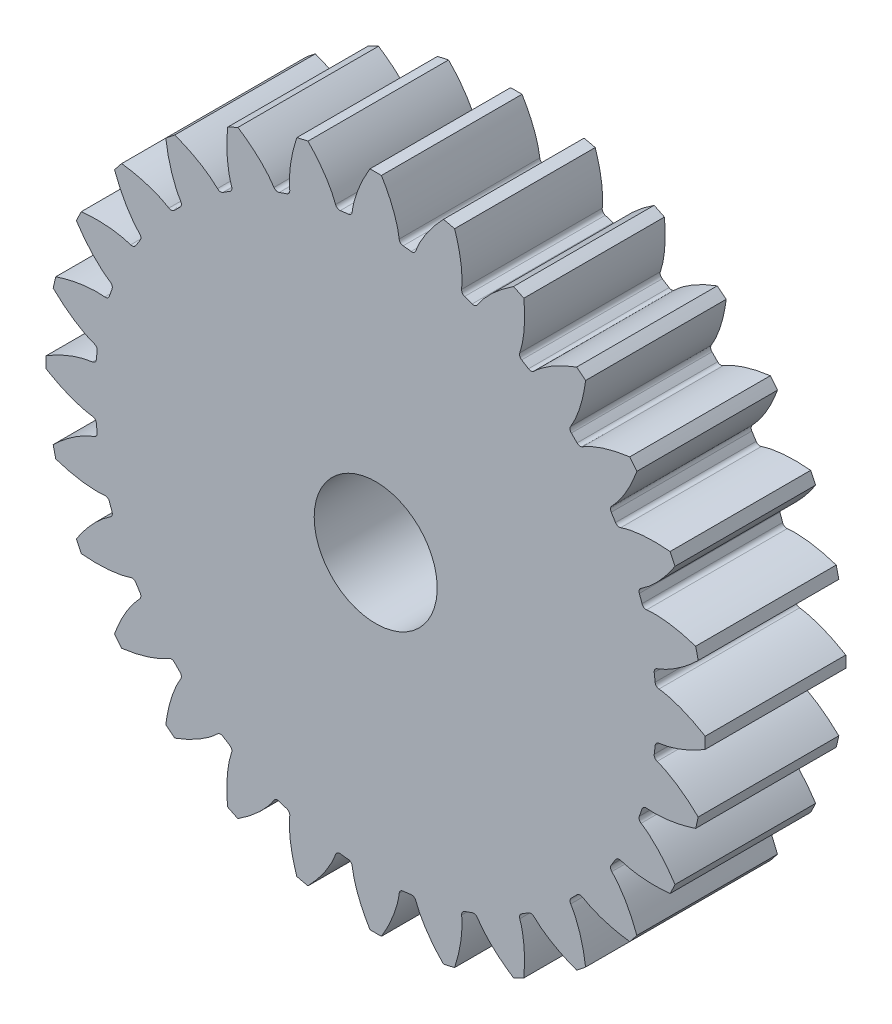
from build123d import *

# Parameters (mm, degrees)
CROQUIS1_R              = 7
SALIENTE_EXTRUIR1_DEPTH = 16


with BuildPart() as part:
    # Croquis1 → Saliente-Extruir1 (new body)
    with BuildSketch(Plane.XY.offset(16)):
        with BuildLine():
            ThreePointArc((26.6938963, -4.031185896), (26.748350108, -3.577124719), (26.796299165, -3.122330636))
            ThreePointArc((26.796299165, -3.122330636), (26.937385185, -2.820846865), (27.236373236, -2.674546235))
            add(Edge.make_bspline(
                [(27.236373236, -2.674546235), (29.642937848, -2.384409161), (32.494335404, -0.652262326)],
                knots=[3.829860465, 3.829860465, 3.829860465, 4.565475677, 4.565475677, 4.565475677], degree=2, weights=[1, 0.933117908, 1]))
            ThreePointArc((32.494335404, -0.652262326), (32.500009079, 5.4516e-05), (32.49433477, 0.652371352))
            add(Edge.make_bspline(
                [(32.49433477, 0.652371352), (29.642538779, 2.385172106), (27.236372217, 2.674655637)],
                knots=[1.705602873, 1.705602873, 1.705602873, 2.450147181, 2.450147181, 2.450147181], degree=2, weights=[1, 0.931503294, 1]))
            ThreePointArc((27.236372217, 2.674655637), (26.937384176, 2.820956256), (26.796298149, 3.122440008))
            ThreePointArc((26.796298149, 3.122440008), (26.748350621, 3.577215817), (26.693898866, 4.031258776))
            ThreePointArc((26.693898866, 4.031258776), (26.764362513, 4.356577558), (27.023298054, 4.565742136))
            add(Edge.make_bspline(
                [(27.023298054, 4.565742136), (29.304963609, 5.384115916), (31.699431838, 7.707330023)],
                knots=[0.688267811, 0.688267811, 0.688267811, 1.423883058, 1.423883058, 1.423883058], degree=2, weights=[1, 0.933117902, 1]))
            ThreePointArc((31.699431838, 7.707330023), (31.559805686, 8.344572282), (31.409115452, 8.979289236))
            add(Edge.make_bspline(
                [(31.409115452, 8.979289236), (28.243235754, 10.034060578), (25.832980864, 9.780863743)],
                knots=[1.705602929, 1.705602929, 1.705602929, 2.450147181, 2.450147181, 2.450147181], degree=2, weights=[1, 0.931503304, 1]))
            ThreePointArc((25.832980864, 9.780863743), (25.508936625, 9.856969646), (25.304298481, 10.119495849))
            ThreePointArc((25.304298481, 10.119495849), (25.15635596, 10.55220015), (25.002235361, 10.982742648))
            ThreePointArc((25.002235361, 10.982742648), (24.998546388, 11.315583457), (25.204442252, 11.577124095))
            add(Edge.make_bspline(
                [(25.204442252, 11.577124095), (27.246796244, 12.882697794), (29.0642663, 15.680483123)],
                knots=[0.688267812, 0.688267812, 0.688267812, 1.42388301, 1.42388301, 1.42388301], degree=2, weights=[1, 0.93311791, 1]))
            ThreePointArc((29.0642663, 15.680483123), (28.786341176, 16.270678535), (28.498191306, 16.855949968))
            add(Edge.make_bspline(
                [(28.498191306, 16.855949968), (25.176978278, 17.179801421), (22.883495213, 16.396620625)],
                knots=[1.70560296, 1.70560296, 1.70560296, 2.450147181, 2.450147181, 2.450147181], degree=2, weights=[1, 0.93150331, 1]))
            ThreePointArc((22.883495213, 16.396620625), (22.550641093, 16.398714506), (22.292714958, 16.609119731))
            ThreePointArc((22.292714958, 16.609119731), (22.052195901, 16.998054924), (21.806134708, 17.383507762))
            ThreePointArc((21.806134708, 17.383507762), (21.728476527, 17.707182576), (21.871009564, 18.007982362))
            add(Edge.make_bspline(
                [(21.871009564, 18.007982362), (23.571639933, 19.735289056), (24.720976404, 22.867353058)],
                knots=[3.829860466, 3.829860466, 3.829860466, 4.565475639, 4.565475639, 4.565475639], degree=2, weights=[1, 0.933117915, 1]))
            ThreePointArc((24.720976404, 22.867353058), (24.318688643, 23.380906834), (23.907528182, 23.887384868))
            add(Edge.make_bspline(
                [(23.907528182, 23.887384868), (20.597521234, 23.464077255), (18.535814735, 22.190184465)],
                knots=[4.847195625, 4.847195625, 4.847195625, 5.591739835, 5.591739835, 5.591739835], degree=2, weights=[1, 0.931503312, 1]))
            ThreePointArc((18.535814735, 22.190184465), (18.210840096, 22.118159884), (17.912560955, 22.265894815))
            ThreePointArc((17.912560955, 22.265894815), (17.59152599, 22.591558065), (17.26586274, 22.91259303))
            ThreePointArc((17.26586274, 22.91259303), (17.118127789, 23.210872177), (17.190152368, 23.535846831))
            add(Edge.make_bspline(
                [(17.190152368, 23.535846831), (18.463782472, 25.598272177), (18.887352876, 28.907560184)],
                knots=[0.688267813, 0.688267813, 0.688267813, 1.423882978, 1.423882978, 1.423882978], degree=2, weights=[1, 0.933117916, 1]))
            ThreePointArc((18.887352876, 28.907560184), (18.380874844, 29.318720646), (17.867321069, 29.721008408))
            add(Edge.make_bspline(
                [(17.867321069, 29.721008408), (14.734497675, 28.57176816), (13.007950258, 26.87104165)],
                knots=[1.705602965, 1.705602965, 1.705602965, 2.450147181, 2.450147181, 2.450147181], degree=2, weights=[1, 0.93150331, 1]))
            ThreePointArc((13.007950258, 26.87104165), (12.707150487, 26.728508615), (12.383475684, 26.806166778))
            ThreePointArc((12.383475684, 26.806166778), (11.998022845, 27.05222797), (11.609087652, 27.292747027))
            ThreePointArc((11.609087652, 27.292747027), (11.398682406, 27.550673163), (11.39658852, 27.883527298))
            add(Edge.make_bspline(
                [(11.39658852, 27.883527298), (12.179353257, 30.177652733), (11.855917987, 33.498223322)],
                knots=[0.688267812, 0.688267812, 0.688267812, 1.42388299, 1.42388299, 1.42388299], degree=2, weights=[1, 0.933117914, 1]))
            ThreePointArc((11.855917987, 33.498223322), (11.270646555, 33.786373193), (10.680451145, 34.064298319))
            add(Edge.make_bspline(
                [(10.680451145, 34.064298319), (7.881904052, 32.246753093), (6.577091985, 30.204474326)],
                knots=[4.847195593, 4.847195593, 4.847195593, 5.591739835, 5.591739835, 5.591739835], degree=2, weights=[1, 0.931503306, 1]))
            ThreePointArc((6.577091985, 30.204474326), (6.315551361, 29.998578466), (5.982710566, 30.002267424))
            ThreePointArc((5.982710566, 30.002267424), (5.552168068, 30.156388023), (5.119463767, 30.304330543))
            ThreePointArc((5.119463767, 30.304330543), (4.856937544, 30.508968685), (4.780831632, 30.833012936))
            add(Edge.make_bspline(
                [(4.780831632, 30.833012936), (5.033479902, 33.243801508), (3.979257264, 36.409147485)],
                knots=[0.688267812, 0.688267812, 0.688267812, 1.42388302, 1.42388302, 1.42388302], degree=2, weights=[1, 0.933117908, 1]))
            ThreePointArc((3.979257264, 36.409147485), (3.344540327, 36.559837717), (2.707298086, 36.699463867))
            add(Edge.make_bspline(
                [(2.707298086, 36.699463867), (0.383358091, 34.304752876), (-0.43428988, 32.023330174)],
                knots=[1.705602901, 1.705602901, 1.705602901, 2.450147181, 2.450147181, 2.450147181], degree=2, weights=[1, 0.931503299, 1]))
            ThreePointArc((-0.43428988, 32.023330174), (-0.643455006, 31.764395442), (-0.968773306, 31.693930923))
            ThreePointArc((-0.968773306, 31.693930923), (-1.422816265, 31.748382677), (-1.877592074, 31.796330205))
            ThreePointArc((-1.877592074, 31.796330205), (-2.179073064, 31.937419401), (-2.325376822, 32.236404617))
            add(Edge.make_bspline(
                [(-2.325376822, 32.236404617), (-2.615513901, 34.642969248), (-4.347660757, 37.494366823)],
                knots=[3.829860465, 3.829860465, 3.829860465, 4.565475683, 4.565475683, 4.565475683], degree=2, weights=[1, 0.933117907, 1]))
            ThreePointArc((-4.347660757, 37.494366823), (-4.999995664, 37.500041132), (-5.652330571, 37.494366827))
            add(Edge.make_bspline(
                [(-5.652330571, 37.494366827), (-7.385130954, 34.642571184), (-7.674614446, 32.23640495)],
                knots=[4.847195619, 4.847195619, 4.847195619, 5.591739835, 5.591739835, 5.591739835], degree=2, weights=[1, 0.93150331, 1]))
            ThreePointArc((-7.674614446, 32.23640495), (-7.820921304, 31.937422565), (-8.122399509, 31.796330202))
            ThreePointArc((-8.122399509, 31.796330202), (-8.577175317, 31.748382674), (-9.031218274, 31.693930919))
            ThreePointArc((-9.031218274, 31.693930919), (-9.35653325, 31.764401622), (-9.565702422, 32.023330592))
            add(Edge.make_bspline(
                [(-9.565702422, 32.023330592), (-10.384076099, 34.304995852), (-12.707289789, 36.699463835)],
                knots=[0.688267813, 0.688267813, 0.688267813, 1.423882972, 1.423882972, 1.423882972], degree=2, weights=[1, 0.933117917, 1]))
            ThreePointArc((-12.707289789, 36.699463835), (-13.344531798, 36.559837735), (-13.979248504, 36.409147562))
            add(Edge.make_bspline(
                [(-13.979248504, 36.409147562), (-15.034019604, 33.243268221), (-14.780822798, 30.833013611)],
                knots=[1.705603007, 1.705603007, 1.705603007, 2.450147181, 2.450147181, 2.450147181], degree=2, weights=[1, 0.931503318, 1]))
            ThreePointArc((-14.780822798, 30.833013611), (-14.856934942, 30.508972879), (-15.11945535, 30.304330533))
            ThreePointArc((-15.11945535, 30.304330533), (-15.552159649, 30.156388013), (-15.982702146, 30.002267414))
            ThreePointArc((-15.982702146, 30.002267414), (-16.315541104, 29.998585123), (-16.577084351, 30.204474563))
            add(Edge.make_bspline(
                [(-16.577084351, 30.204474563), (-17.882657907, 32.246828325), (-20.680442837, 34.064298254)],
                knots=[0.688267813, 0.688267813, 0.688267813, 1.423882936, 1.423882936, 1.423882936], degree=2, weights=[1, 0.933117924, 1]))
            ThreePointArc((-20.680442837, 34.064298254), (-21.270638043, 33.786373224), (-21.855909274, 33.498223455))
            add(Edge.make_bspline(
                [(-21.855909274, 33.498223455), (-22.179760585, 30.177010793), (-21.396579873, 27.883527969)],
                knots=[4.847195685, 4.847195685, 4.847195685, 5.591739835, 5.591739835, 5.591739835], degree=2, weights=[1, 0.931503322, 1]))
            ThreePointArc((-21.396579873, 27.883527969), (-21.398679976, 27.55067569), (-21.609079232, 27.29274701))
            ThreePointArc((-21.609079232, 27.29274701), (-21.998014423, 27.052227953), (-22.38346726, 26.806166762))
            ThreePointArc((-22.38346726, 26.806166762), (-22.707141782, 26.728514962), (-23.007942594, 26.871041693))
            add(Edge.make_bspline(
                [(-23.007942594, 26.871041693), (-24.735249112, 28.571671885), (-27.867312729, 29.721008324)],
                knots=[0.688267814, 0.688267814, 0.688267814, 1.423882917, 1.423882917, 1.423882917], degree=2, weights=[1, 0.933117927, 1]))
            ThreePointArc((-27.867312729, 29.721008324), (-28.380866337, 29.318720693), (-28.887344206, 28.907560368))
            add(Edge.make_bspline(
                [(-28.887344206, 28.907560368), (-28.464036539, 25.597553793), (-27.190143878, 23.535847502)],
                knots=[4.847195694, 4.847195694, 4.847195694, 5.591739835, 5.591739835, 5.591739835], degree=2, weights=[1, 0.931503324, 1]))
            ThreePointArc((-27.190143878, 23.535847502), (-27.118125536, 23.210873258), (-27.265854315, 22.912593007))
            ThreePointArc((-27.265854315, 22.912593007), (-27.591517564, 22.591558043), (-27.912552528, 22.265894794))
            ThreePointArc((-27.912552528, 22.265894794), (-28.210832786, 22.118165994), (-28.535807045, 22.190184334))
            add(Edge.make_bspline(
                [(-28.535807045, 22.190184334), (-30.598232186, 23.463814308), (-33.907519819, 23.887384765)],
                knots=[0.688267814, 0.688267814, 0.688267814, 1.423882912, 1.423882912, 1.423882912], degree=2, weights=[1, 0.933117928, 1]))
            ThreePointArc((-33.907519819, 23.887384765), (-34.318680145, 23.380906896), (-34.720967777, 22.86735329))
            add(Edge.make_bspline(
                [(-34.720967777, 22.86735329), (-33.57172756, 19.73453028), (-31.871001226, 18.007983042)],
                knots=[1.705603035, 1.705603035, 1.705603035, 2.450147181, 2.450147181, 2.450147181], degree=2, weights=[1, 0.931503323, 1]))
            ThreePointArc((-31.871001226, 18.007983042), (-31.728474497, 17.707182245), (-31.806126278, 17.383507735))
            ThreePointArc((-31.806126278, 17.383507735), (-32.052187469, 16.998054897), (-32.292706525, 16.609119706))
            ThreePointArc((-32.292706525, 16.609119706), (-32.550635206, 16.398720429), (-32.883487501, 16.39662032))
            add(Edge.make_bspline(
                [(-32.883487501, 16.39662032), (-35.177612698, 17.179384973), (-38.49818292, 16.855949842)],
                knots=[0.688267814, 0.688267814, 0.688267814, 1.42388292, 1.42388292, 1.42388292], degree=2, weights=[1, 0.933117927, 1]))
            ThreePointArc((-38.49818292, 16.855949842), (-38.78633269, 16.270678612), (-39.064257721, 15.680483407))
            add(Edge.make_bspline(
                [(-39.064257721, 15.680483407), (-37.246712621, 12.881936713), (-35.204434083, 11.577124793)],
                knots=[4.847195669, 4.847195669, 4.847195669, 5.591739835, 5.591739835, 5.591739835], degree=2, weights=[1, 0.93150332, 1]))
            ThreePointArc((-35.204434083, 11.577124793), (-34.998544648, 11.315581561), (-35.002226924, 10.982742617))
            ThreePointArc((-35.002226924, 10.982742617), (-35.156347522, 10.552200121), (-35.304290042, 10.119495821))
            ThreePointArc((-35.304290042, 10.119495821), (-35.508932385, 9.856975392), (-35.83297313, 9.78086324))
            add(Edge.make_bspline(
                [(-35.83297313, 9.78086324), (-38.243761425, 10.033511477), (-41.409107042, 8.97928908)],
                knots=[0.688267813, 0.688267813, 0.688267813, 1.423882944, 1.423882944, 1.423882944], degree=2, weights=[1, 0.933117922, 1]))
            ThreePointArc((-41.409107042, 8.97928908), (-41.559797217, 8.344572375), (-41.699423318, 7.707330368))
            add(Edge.make_bspline(
                [(-41.699423318, 7.707330368), (-39.304712541, 5.38339074), (-37.023290099, 4.565742862)],
                knots=[4.847195632, 4.847195632, 4.847195632, 5.591739835, 5.591739835, 5.591739835], degree=2, weights=[1, 0.931503313, 1]))
            ThreePointArc((-37.023290099, 4.565742862), (-36.764361137, 4.356573703), (-36.693890422, 4.031258745))
            ThreePointArc((-36.693890422, 4.031258745), (-36.748342176, 3.577215787), (-36.796289703, 3.122439979))
            ThreePointArc((-36.796289703, 3.122439979), (-36.937382059, 2.820961755), (-37.236364455, 2.674654885))
            add(Edge.make_bspline(
                [(-37.236364455, 2.674654885), (-39.642928924, 2.384517825), (-42.494326325, 0.652371152)],
                knots=[3.829860466, 3.829860466, 3.829860466, 4.565475638, 4.565475638, 4.565475638], degree=2, weights=[1, 0.933117915, 1]))
            ThreePointArc((-42.494326325, 0.652371152), (-42.50000063, 3.6317e-05), (-42.494326326, -0.652298518))
            add(Edge.make_bspline(
                [(-42.494326326, -0.652298518), (-39.642530683, -2.385098901), (-37.236364449, -2.674582393)],
                knots=[4.847195619, 4.847195619, 4.847195619, 5.591739835, 5.591739835, 5.591739835], degree=2, weights=[1, 0.93150331, 1]))
            ThreePointArc((-37.236364449, -2.674582393), (-36.937382064, -2.820889251), (-36.7962897, -3.122367456))
            ThreePointArc((-36.7962897, -3.122367456), (-36.748342173, -3.577143264), (-36.693890418, -4.031186222))
            ThreePointArc((-36.693890418, -4.031186222), (-36.764361121, -4.356501198), (-37.023290091, -4.56567037))
            add(Edge.make_bspline(
                [(-37.023290091, -4.56567037), (-39.304955351, -5.384044047), (-41.699423334, -7.707257736)],
                knots=[3.829860466, 3.829860466, 3.829860466, 4.565475626, 4.565475626, 4.565475626], degree=2, weights=[1, 0.933117917, 1]))
            ThreePointArc((-41.699423334, -7.707257736), (-41.559797234, -8.344499745), (-41.40910706, -8.979216451))
            add(Edge.make_bspline(
                [(-41.40910706, -8.979216451), (-38.24322772, -10.033987552), (-35.83297311, -9.780790746)],
                knots=[1.705603007, 1.705603007, 1.705603007, 2.450147181, 2.450147181, 2.450147181], degree=2, weights=[1, 0.931503318, 1]))
            ThreePointArc((-35.83297311, -9.780790746), (-35.508932378, -9.856902889), (-35.304290032, -10.119423297))
            ThreePointArc((-35.304290032, -10.119423297), (-35.156347511, -10.552127597), (-35.002226913, -10.982670093))
            ThreePointArc((-35.002226913, -10.982670093), (-34.998544622, -11.315509052), (-35.204434061, -11.577052298))
            add(Edge.make_bspline(
                [(-35.204434061, -11.577052298), (-37.246787824, -12.882625854), (-39.064257753, -15.680410784)],
                knots=[3.829860467, 3.829860467, 3.829860467, 4.56547559, 4.56547559, 4.56547559], degree=2, weights=[1, 0.933117924, 1]))
            ThreePointArc((-39.064257753, -15.680410784), (-38.786332723, -16.27060599), (-38.498182954, -16.855877221))
            add(Edge.make_bspline(
                [(-38.498182954, -16.855877221), (-35.176970292, -17.179728533), (-32.883487468, -16.39654782)],
                knots=[4.847195685, 4.847195685, 4.847195685, 5.591739835, 5.591739835, 5.591739835], degree=2, weights=[1, 0.931503322, 1]))
            ThreePointArc((-32.883487468, -16.39654782), (-32.550635188, -16.398647924), (-32.292706509, -16.609047179))
            ThreePointArc((-32.292706509, -16.609047179), (-32.052187452, -16.99798237), (-31.80612626, -17.383435208))
            ThreePointArc((-31.80612626, -17.383435208), (-31.728474461, -17.707109729), (-31.871001191, -18.007910541))
            add(Edge.make_bspline(
                [(-31.871001191, -18.007910541), (-33.571631384, -19.735217059), (-34.720967823, -22.867280677)],
                knots=[0.688267814, 0.688267814, 0.688267814, 1.423882917, 1.423882917, 1.423882917], degree=2, weights=[1, 0.933117927, 1]))
            ThreePointArc((-34.720967823, -22.867280677), (-34.318680192, -23.380834284), (-33.907519866, -23.887312154))
            add(Edge.make_bspline(
                [(-33.907519866, -23.887312154), (-30.597513291, -23.464004486), (-28.535807001, -22.190111826)],
                knots=[4.847195694, 4.847195694, 4.847195694, 5.591739835, 5.591739835, 5.591739835], degree=2, weights=[1, 0.931503324, 1]))
            ThreePointArc((-28.535807001, -22.190111826), (-28.210832757, -22.118093483), (-27.912552506, -22.265822263))
            ThreePointArc((-27.912552506, -22.265822263), (-27.591517542, -22.591485511), (-27.265854293, -22.912520475))
            ThreePointArc((-27.265854293, -22.912520475), (-27.118125493, -23.210800733), (-27.190143833, -23.535774992))
            add(Edge.make_bspline(
                [(-27.190143833, -23.535774992), (-28.463773807, -25.598200133), (-28.887344264, -28.907487766)],
                knots=[3.829860467, 3.829860467, 3.829860467, 4.565475565, 4.565475565, 4.565475565], degree=2, weights=[1, 0.933117928, 1]))
            ThreePointArc((-28.887344264, -28.907487766), (-28.380866395, -29.318648093), (-27.867312789, -29.720935725))
            add(Edge.make_bspline(
                [(-27.867312789, -29.720935725), (-24.734489779, -28.571695507), (-23.007942541, -26.870969173)],
                knots=[4.847195689, 4.847195689, 4.847195689, 5.591739835, 5.591739835, 5.591739835], degree=2, weights=[1, 0.931503323, 1]))
            ThreePointArc((-23.007942541, -26.870969173), (-22.707141744, -26.728442444), (-22.383467234, -26.806094225))
            ThreePointArc((-22.383467234, -26.806094225), (-21.998014396, -27.052155416), (-21.609079205, -27.292674473))
            ThreePointArc((-21.609079205, -27.292674473), (-21.398679928, -27.550603154), (-21.396579819, -27.883455448))
            add(Edge.make_bspline(
                [(-21.396579819, -27.883455448), (-22.179344472, -30.177580645), (-21.855909341, -33.498150868)],
                knots=[3.829860467, 3.829860467, 3.829860467, 4.565475574, 4.565475574, 4.565475574], degree=2, weights=[1, 0.933117927, 1]))
            ThreePointArc((-21.855909341, -33.498150868), (-21.270638111, -33.786300637), (-20.680442906, -34.064225668))
            add(Edge.make_bspline(
                [(-20.680442906, -34.064225668), (-17.881896212, -32.246680568), (-16.577084292, -30.20440203)],
                knots=[4.847195669, 4.847195669, 4.847195669, 5.591739835, 5.591739835, 5.591739835], degree=2, weights=[1, 0.93150332, 1]))
            ThreePointArc((-16.577084292, -30.20440203), (-16.31554106, -29.998512595), (-15.982702116, -30.002194871))
            ThreePointArc((-15.982702116, -30.002194871), (-15.55215962, -30.156315469), (-15.11945532, -30.304257989))
            ThreePointArc((-15.11945532, -30.304257989), (-14.856934891, -30.508900332), (-14.780822739, -30.832941077))
            add(Edge.make_bspline(
                [(-14.780822739, -30.832941077), (-15.033470976, -33.243729372), (-13.979248579, -36.409074989)],
                knots=[3.829860467, 3.829860467, 3.829860467, 4.565475597, 4.565475597, 4.565475597], degree=2, weights=[1, 0.933117922, 1]))
            ThreePointArc((-13.979248579, -36.409074989), (-13.344531874, -36.559765164), (-12.707289866, -36.699391265))
            add(Edge.make_bspline(
                [(-12.707289866, -36.699391265), (-10.383350239, -34.304680488), (-9.565702361, -32.023258046)],
                knots=[4.847195632, 4.847195632, 4.847195632, 5.591739835, 5.591739835, 5.591739835], degree=2, weights=[1, 0.931503313, 1]))
            ThreePointArc((-9.565702361, -32.023258046), (-9.356533202, -31.764329085), (-9.031218244, -31.693858369))
            ThreePointArc((-9.031218244, -31.693858369), (-8.577175286, -31.748310124), (-8.122399478, -31.796257651))
            ThreePointArc((-8.122399478, -31.796257651), (-7.820921254, -31.937350007), (-7.674614384, -32.236332402))
            add(Edge.make_bspline(
                [(-7.674614384, -32.236332402), (-7.384477323, -34.642896871), (-5.652330651, -37.494294272)],
                knots=[3.829860466, 3.829860466, 3.829860466, 4.565475638, 4.565475638, 4.565475638], degree=2, weights=[1, 0.933117915, 1]))
            ThreePointArc((-5.652330651, -37.494294272), (-4.999995746, -37.499968578), (-4.347660841, -37.494294271))
            add(Edge.make_bspline(
                [(-4.347660841, -37.494294271), (-2.614860273, -34.642498455), (-2.325376762, -32.236332057)],
                knots=[1.705602919, 1.705602919, 1.705602919, 2.450147181, 2.450147181, 2.450147181], degree=2, weights=[1, 0.931503302, 1]))
            ThreePointArc((-2.325376762, -32.236332057), (-2.179073015, -31.937346852), (-1.877592044, -31.796257648))
            ThreePointArc((-1.877592044, -31.796257648), (-1.422816235, -31.74831012), (-0.968773276, -31.693858365))
            ThreePointArc((-0.968773276, -31.693858365), (-0.643454959, -31.764322873), (-0.43428982, -32.023257612))
            add(Edge.make_bspline(
                [(-0.43428982, -32.023257612), (0.384083947, -34.304923131), (2.707298003, -36.69939133)],
                knots=[0.688267811, 0.688267811, 0.688267811, 1.423883047, 1.423883047, 1.423883047], degree=2, weights=[1, 0.933117904, 1]))
            ThreePointArc((2.707298003, -36.69939133), (3.344540245, -36.559765182), (3.979257184, -36.409074951))
            add(Edge.make_bspline(
                [(3.979257184, -36.409074951), (5.034028526, -33.243195253), (4.78083169, -30.832940363)],
                knots=[1.705602929, 1.705602929, 1.705602929, 2.450147181, 2.450147181, 2.450147181], degree=2, weights=[1, 0.931503304, 1]))
            ThreePointArc((4.78083169, -30.832940363), (4.856937594, -30.508896124), (5.119463796, -30.30425798))
            ThreePointArc((5.119463796, -30.30425798), (5.552168097, -30.156315459), (5.982710595, -30.00219486))
            ThreePointArc((5.982710595, -30.00219486), (6.315551404, -29.998505886), (6.577092043, -30.204401751))
            add(Edge.make_bspline(
                [(6.577092043, -30.204401751), (7.882665741, -32.246755742), (10.680451071, -34.064225799)],
                knots=[0.688267812, 0.688267812, 0.688267812, 1.42388301, 1.42388301, 1.42388301], degree=2, weights=[1, 0.93311791, 1]))
            ThreePointArc((10.680451071, -34.064225799), (11.270646482, -33.786300675), (11.855917915, -33.498150805))
            add(Edge.make_bspline(
                [(11.855917915, -33.498150805), (12.179769368, -30.176937777), (11.396588573, -27.883454712)],
                knots=[1.70560296, 1.70560296, 1.70560296, 2.450147181, 2.450147181, 2.450147181], degree=2, weights=[1, 0.93150331, 1]))
            ThreePointArc((11.396588573, -27.883454712), (11.398682454, -27.550600592), (11.609087679, -27.292674457))
            ThreePointArc((11.609087679, -27.292674457), (11.998022871, -27.052155399), (12.383475709, -26.806094207))
            ThreePointArc((12.383475709, -26.806094207), (12.707150523, -26.728436026), (13.00795031, -26.870969063))
            add(Edge.make_bspline(
                [(13.00795031, -26.870969063), (14.735257003, -28.571599432), (17.867321005, -29.720935903)],
                knots=[3.829860466, 3.829860466, 3.829860466, 4.565475639, 4.565475639, 4.565475639], degree=2, weights=[1, 0.933117915, 1]))
            ThreePointArc((17.867321005, -29.720935903), (18.380874781, -29.318648142), (18.887352815, -28.907487681))
            add(Edge.make_bspline(
                [(18.887352815, -28.907487681), (18.464045202, -25.597480733), (17.190152412, -23.535774234)],
                knots=[1.705602972, 1.705602972, 1.705602972, 2.450147181, 2.450147181, 2.450147181], degree=2, weights=[1, 0.931503312, 1]))
            ThreePointArc((17.190152412, -23.535774234), (17.118127831, -23.210799595), (17.265862763, -22.912520454))
            ThreePointArc((17.265862763, -22.912520454), (17.591526012, -22.591485489), (17.912560977, -22.265822239))
            ThreePointArc((17.912560977, -22.265822239), (18.210840124, -22.118087288), (18.535814778, -22.190111867))
            add(Edge.make_bspline(
                [(18.535814778, -22.190111867), (20.598240124, -23.463741971), (23.907528132, -23.887312375)],
                knots=[3.829860466, 3.829860466, 3.829860466, 4.565475632, 4.565475632, 4.565475632], degree=2, weights=[1, 0.933117916, 1]))
            ThreePointArc((23.907528132, -23.887312375), (24.318688594, -23.380834343), (24.720976355, -22.867280568))
            add(Edge.make_bspline(
                [(24.720976355, -22.867280568), (23.571736107, -19.734457173), (21.871009597, -18.007909757)],
                knots=[4.847195619, 4.847195619, 4.847195619, 5.591739835, 5.591739835, 5.591739835], degree=2, weights=[1, 0.93150331, 1]))
            ThreePointArc((21.871009597, -18.007909757), (21.728476562, -17.707109986), (21.806134725, -17.383435182))
            ThreePointArc((21.806134725, -17.383435182), (22.052195917, -16.997982344), (22.292714974, -16.609047151))
            ThreePointArc((22.292714974, -16.609047151), (22.55064111, -16.398641905), (22.883495245, -16.396548019))
            add(Edge.make_bspline(
                [(22.883495245, -16.396548019), (25.17762068, -17.179312756), (28.498191269, -16.855877486)],
                knots=[3.829860466, 3.829860466, 3.829860466, 4.565475643, 4.565475643, 4.565475643], degree=2, weights=[1, 0.933117914, 1]))
            ThreePointArc((28.498191269, -16.855877486), (28.786341141, -16.270606054), (29.064266266, -15.680410644))
            add(Edge.make_bspline(
                [(29.064266266, -15.680410644), (27.246721041, -12.881863551), (25.204442273, -11.577051484)],
                knots=[1.705602939, 1.705602939, 1.705602939, 2.450147181, 2.450147181, 2.450147181], degree=2, weights=[1, 0.931503306, 1]))
            ThreePointArc((25.204442273, -11.577051484), (24.998546413, -11.31551086), (25.002235371, -10.982670065))
            ThreePointArc((25.002235371, -10.982670065), (25.15635597, -10.552127567), (25.30429849, -10.119423266))
            ThreePointArc((25.30429849, -10.119423266), (25.508936632, -9.856897043), (25.832980883, -9.780791131))
            add(Edge.make_bspline(
                [(25.832980883, -9.780791131), (28.243769455, -10.0334394), (31.409115432, -8.979216763)],
                knots=[3.829860465, 3.829860465, 3.829860465, 4.565475674, 4.565475674, 4.565475674], degree=2, weights=[1, 0.933117908, 1]))
            ThreePointArc((31.409115432, -8.979216763), (31.559801615, -8.344517566), (31.699424334, -7.7072932))
            add(Edge.make_bspline(
                [(31.699424334, -7.7072932), (29.304713522, -5.383353511), (27.023291036, -4.565705617)],
                knots=[4.847195619, 4.847195619, 4.847195619, 5.591739835, 5.591739835, 5.591739835], degree=2, weights=[1, 0.93150331, 1]))
            ThreePointArc((27.023291036, -4.565705617), (26.764354768, -4.356519942), (26.6938963, -4.031185896))
        make_face()
        with Locations((-4.999995776, 3.6277e-05)):
            Circle(CROQUIS1_R, mode=Mode.SUBTRACT)
    extrude(amount=-SALIENTE_EXTRUIR1_DEPTH)


solid = part.part
